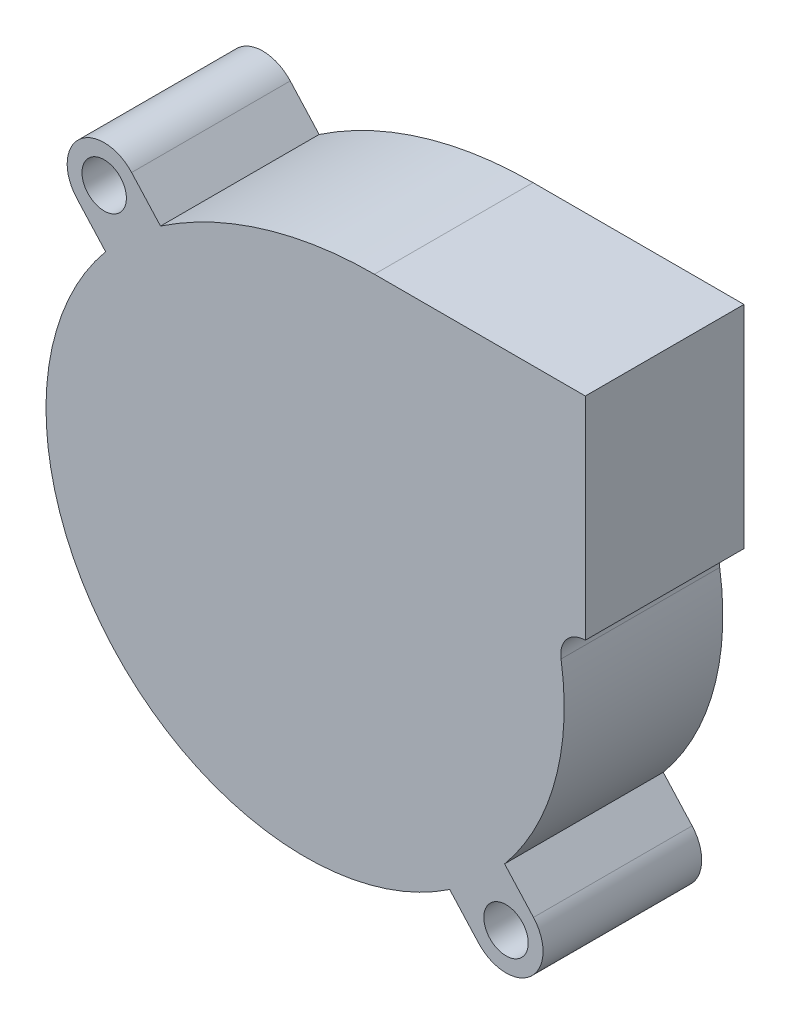
from build123d import *

# Parameters (mm, degrees)
SKETCH1_R           = 2.1
BOSS_EXTRUDE1_DEPTH = 15


with BuildPart() as part:
    # Sketch1 → Boss-Extrude1 (new body)
    with BuildSketch(Plane.XY):
        with BuildLine():
            Line((-21.595375227, 18.651803366), (-18.864158731, 15.633090397))
            ThreePointArc((-18.864158731, 15.633090397), (-18.167626589, -16.437376437), (13.673408277, -20.329483665))
            Line((13.673408277, -20.329483665), (16.404624773, -23.348196634))
            ThreePointArc((16.404624773, -23.348196634), (21.348196634, -23.595375227), (21.595375227, -18.651803366))
            Line((21.595375227, -18.651803366), (18.864158731, -15.633090397))
            ThreePointArc((18.864158731, -15.633090397), (23.626039946, -6.485386377), (24.201713513, 3.811438449))
            ThreePointArc((24.201713513, 3.811438449), (24.731491872, 5.685176303), (26.5, 6.5))
            Line((26.5, 6.5), (26.5, 26.5))
            Line((26.5, 26.5), (6.557177663, 26.5))
            ThreePointArc((6.557177663, 26.5), (-4.018169605, 24.923070714), (-13.673408277, 20.329483665))
            Line((-13.673408277, 20.329483665), (-16.404624773, 23.348196634))
            ThreePointArc((-16.404624773, 23.348196634), (-21.348196634, 23.595375227), (-21.595375227, 18.651803366))
        make_face()
        with Locations((-19, 21)):
            Circle(SKETCH1_R, mode=Mode.SUBTRACT)
        with Locations((19, -21)):
            Circle(SKETCH1_R, mode=Mode.SUBTRACT)
    extrude(amount=BOSS_EXTRUDE1_DEPTH)


solid = part.part
